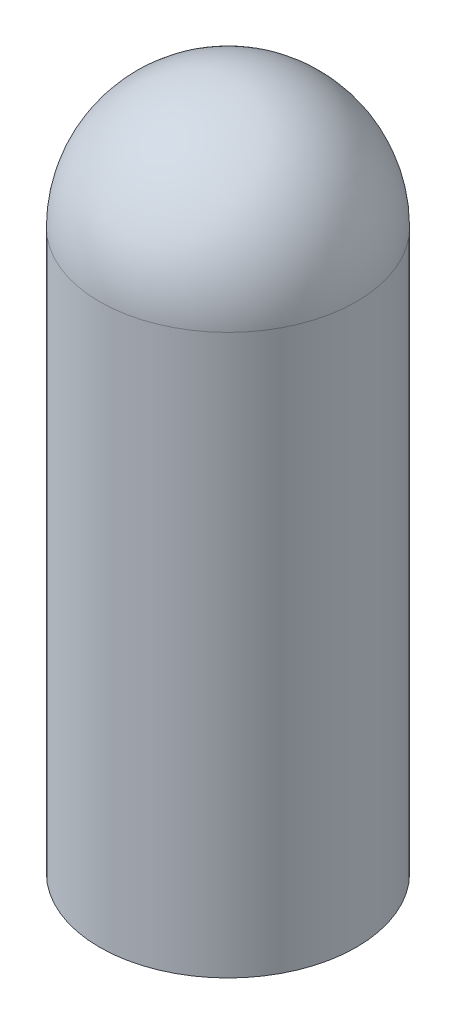
from build123d import *

# Parameters (mm, degrees)
SKETCH2_R          = 5.5499
CUT_EXTRUDE1_DEPTH = 27.7749


with BuildPart() as part:
    # Sketch1 → Revolve1 (revolve)
    with BuildSketch(Plane.XY):
        with BuildLine():
            Line((-5.9309, 0), (-5.9309, 25.8191))
            ThreePointArc((-5.9309, 25.8191), (-4.193779609, 30.012879609), (0, 31.75))
            Line((0, 31.75), (0, 0))
            Line((0, 0), (-5.9309, 0))
        make_face()
    revolve(axis=Axis((0, 0, 0), (0, -1, 0)))

    # Sketch2 → Cut-Extrude1 (cut)
    with BuildSketch(Plane.XZ):
        Circle(SKETCH2_R)
    extrude(amount=-CUT_EXTRUDE1_DEPTH, mode=Mode.SUBTRACT)


solid = part.part
